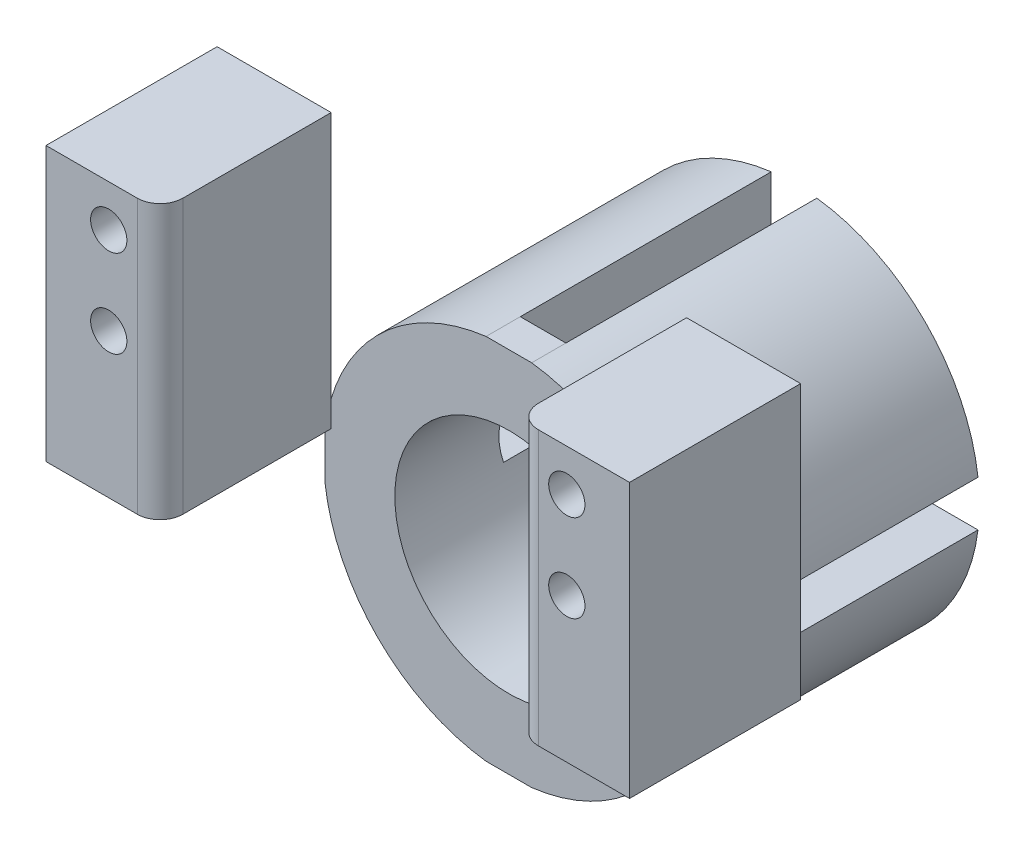
from build123d import *

# Parameters (mm, degrees)
BOSS_EXTRUDE3_DEPTH   = 31.75
BOSS_EXTRUDE3_2_DEPTH = 31.75
BOSS_EXTRUDE3_3_DEPTH = 31.75
BOSS_EXTRUDE3_4_DEPTH = 31.75
BOSS_EXTRUDE4_DEPTH   = 5.08
CIRPATTERN2_COUNT     = 4
CUT_EXTRUDE1_DEPTH    = 47.752
BOSS_EXTRUDE6_DEPTH   = 19.05
SKETCH12_R            = 2.0193
CUT_EXTRUDE2_DEPTH    = 5.461
FILLET5_R             = 2.54


with BuildPart() as part:
    # Sketch4 → Boss-Extrude3 (new body)
    with BuildSketch(Plane.XY):
        with BuildLine():
            Line((-20.480595847, 2.54), (-12.443407893, 2.54))
            ThreePointArc((-12.443407893, 2.54), (-8.980256121, 8.980256121), (-2.54, 12.443407893))
            Line((-2.54, 12.443407893), (-2.54, 20.480595847))
            ThreePointArc((-2.54, 20.480595847), (-14.592916197, 14.592916197), (-20.480595847, 2.54))
        make_face()
    extrude(amount=-BOSS_EXTRUDE3_DEPTH)


with BuildPart() as body_2:
    # Sketch4 → Boss-Extrude3 2 (new body)
    with BuildSketch(Plane.XY):
        with BuildLine():
            ThreePointArc((-2.54, -12.443407893), (-8.980256121, -8.980256121), (-12.443407893, -2.54))
            Line((-12.443407893, -2.54), (-20.480595847, -2.54))
            ThreePointArc((-20.480595847, -2.54), (-14.592916197, -14.592916197), (-2.54, -20.480595847))
            Line((-2.54, -20.480595847), (-2.54, -12.443407893))
        make_face()
    extrude(amount=-BOSS_EXTRUDE3_2_DEPTH)


with BuildPart() as body_3:
    # Sketch4 → Boss-Extrude3 3 (new body)
    with BuildSketch(Plane.XY):
        with BuildLine():
            Line((2.54, 20.480595847), (2.54, 12.443407893))
            ThreePointArc((2.54, 12.443407893), (8.980256121, 8.980256121), (12.443407893, 2.54))
            Line((12.443407893, 2.54), (20.480595847, 2.54))
            ThreePointArc((20.480595847, 2.54), (14.592916197, 14.592916197), (2.54, 20.480595847))
        make_face()
    extrude(amount=-BOSS_EXTRUDE3_3_DEPTH)


with BuildPart() as body_4:
    # Sketch4 → Boss-Extrude3 4 (new body)
    with BuildSketch(Plane.XY):
        with BuildLine():
            ThreePointArc((12.443407893, -2.54), (8.980256121, -8.980256121), (2.54, -12.443407893))
            Line((2.54, -12.443407893), (2.54, -20.480595847))
            ThreePointArc((2.54, -20.480595847), (14.592916197, -14.592916197), (20.480595847, -2.54))
            Line((20.480595847, -2.54), (12.443407893, -2.54))
        make_face()
    extrude(amount=-BOSS_EXTRUDE3_4_DEPTH)


with BuildPart() as body_5:
    # Sketch7 → Boss-Extrude4 (new body)
    with BuildSketch(Plane.XZ.offset(-2.54)):
        Polygon((12.443407893, 0), (12.443407893, -11.847187954), (20.480595847, -3.81), (20.480595847, 0), align=None)
    extrude(amount=BOSS_EXTRUDE4_DEPTH)


with BuildPart() as cirpattern2_1:
    # CirPattern2: pattern copy
    add(body_5.part.rotate(Axis((0, 0, 0), (0, 0, 1)), 1 * 360 / CIRPATTERN2_COUNT))


with BuildPart() as cirpattern2_2:
    # CirPattern2: pattern copy
    add(body_5.part.rotate(Axis((0, 0, 0), (0, 0, 1)), 2 * 360 / CIRPATTERN2_COUNT))


with BuildPart() as cirpattern2_3:
    # CirPattern2: pattern copy
    add(body_5.part.rotate(Axis((0, 0, 0), (0, 0, 1)), 3 * 360 / CIRPATTERN2_COUNT))


with BuildPart() as body_3_1:
    add(body_3.part)

    # Combine1: union CirPattern2_2, body 2, CirPattern2_3, body 4, body 5, CirPattern2_1, part
    add(cirpattern2_2.part)
    add(body_2.part)
    add(cirpattern2_3.part)
    add(body_4.part)
    add(body_5.part)
    add(cirpattern2_1.part)
    add(part.part)

    # Sketch8 → Cut-Extrude1 (cut)
    with BuildSketch(Plane.XY):
        with BuildLine():
            Line((-2.54, 12.443407893), (2.54, 12.443407893))
            ThreePointArc((2.54, 12.443407893), (0, 12.7), (-2.54, 12.443407893))
        make_face()
        with BuildLine():
            Line((12.443407893, 2.54), (12.443407893, -2.54))
            ThreePointArc((12.443407893, -2.54), (12.635689143, -1.276463817), (12.7, 0))
            ThreePointArc((12.7, 0), (12.635689143, 1.276463817), (12.443407893, 2.54))
        make_face()
        with BuildLine():
            ThreePointArc((-2.54, -12.443407893), (0, -12.7), (2.54, -12.443407893))
            Line((2.54, -12.443407893), (-2.54, -12.443407893))
        make_face()
        with BuildLine():
            ThreePointArc((-12.443407893, 2.54), (-12.7, 0), (-12.443407893, -2.54))
            Line((-12.443407893, -2.54), (-12.443407893, 2.54))
        make_face()
    extrude(amount=-CUT_EXTRUDE1_DEPTH, mode=Mode.SUBTRACT)

    # Sketch11 → Boss-Extrude6 (add)
    with BuildSketch(Plane.XY):
        Polygon((-19.785000054, 33.446844079), (-32.485000054, 33.446844079), (-32.485000054, 14.396844079), (-32.485000054, 2.966844079), (-19.785000054, 2.966844079), align=None)
        Polygon((32.485000054, 33.446844079), (32.485000054, 14.396844079), (32.485000054, 2.966844079), (19.785000054, 2.966844079), (19.785000054, 33.446844079), align=None)
    extrude(amount=BOSS_EXTRUDE6_DEPTH)

    # Sketch12 → Cut-Extrude2 (cut)
    with BuildSketch(Plane.XY.offset(19.05)):
        with Locations((25.500000054, 28.793688158)):
            Circle(SKETCH12_R)
        with Locations((25.500000054, 19.05)):
            Circle(SKETCH12_R)
        with Locations((-25.500000054, 28.793688158)):
            Circle(SKETCH12_R)
        with Locations((-25.500000054, 19.05)):
            Circle(SKETCH12_R)
    extrude(amount=-CUT_EXTRUDE2_DEPTH, mode=Mode.SUBTRACT)

    # Fillet5
    fillet5_edges = [body_3_1.edges().sort_by_distance(p)[0] for p in [
        (-19.785000054, 18.206844079, 19.05),
        (19.785000054, 18.206844079, 19.05),
    ]]
    fillet(fillet5_edges, radius=FILLET5_R)


solid = body_3_1.part
